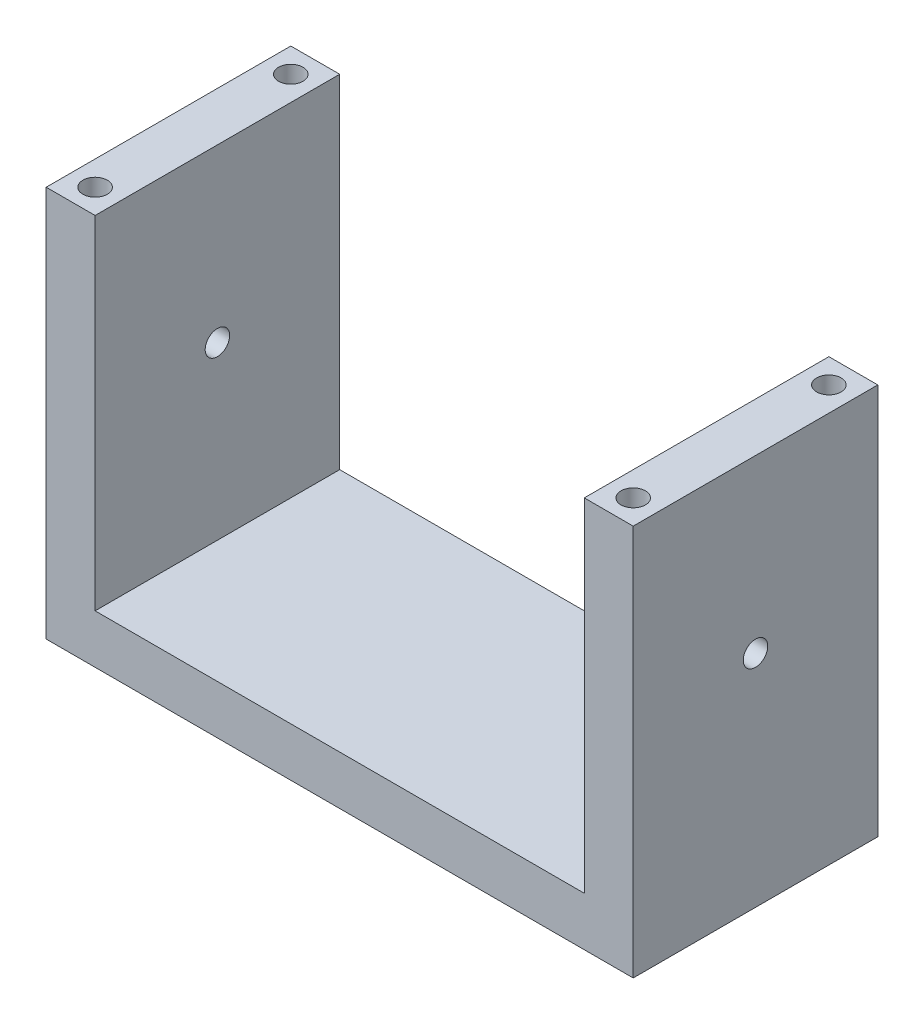
from build123d import *

# Parameters (mm, degrees)
BOSS_EXTRUDE1_DEPTH     = 5
SKETCH2_R               = 0.25
CUT_EXTRUDE1_DEPTH      = 9
SKETCH4_R               = 0.25
CUT_EXTRUDE2_DEPTH      = 10
CUT_EXTRUDE2_DEPTH_BACK = 10


with BuildPart() as part:
    # Sketch1 → Boss-Extrude1 (new body)
    with BuildSketch(Plane.XY):
        Polygon((-6, 8), (-5, 8), (-5, 1), (5, 1), (5, 8), (6, 8), (6, 0), (-6, 0), align=None)
    extrude(amount=BOSS_EXTRUDE1_DEPTH)

    # Sketch2 → Cut-Extrude1 (cut, through all)
    with BuildSketch(Plane.XZ):
        with Locations((-5.5, 4.5)):
            Circle(SKETCH2_R)
        with Locations((-5.5, 0.5)):
            Circle(SKETCH2_R)
        with Locations((5.5, 4.5)):
            Circle(SKETCH2_R)
        with Locations((5.5, 0.5)):
            Circle(SKETCH2_R)
    extrude(amount=-CUT_EXTRUDE1_DEPTH, mode=Mode.SUBTRACT)

    # Sketch4 → Cut-Extrude2 (cut, two sides)
    with BuildSketch(Plane(origin=(0, 0, 0), x_dir=(0, 0, -1), z_dir=(1, 0, 0))) as cut_extrude2_sk:
        with Locations((-2.5, 4.5)):
            Circle(SKETCH4_R)
    extrude(amount=CUT_EXTRUDE2_DEPTH, mode=Mode.SUBTRACT)
    extrude(cut_extrude2_sk.sketch, amount=-CUT_EXTRUDE2_DEPTH_BACK, mode=Mode.SUBTRACT)


solid = part.part
